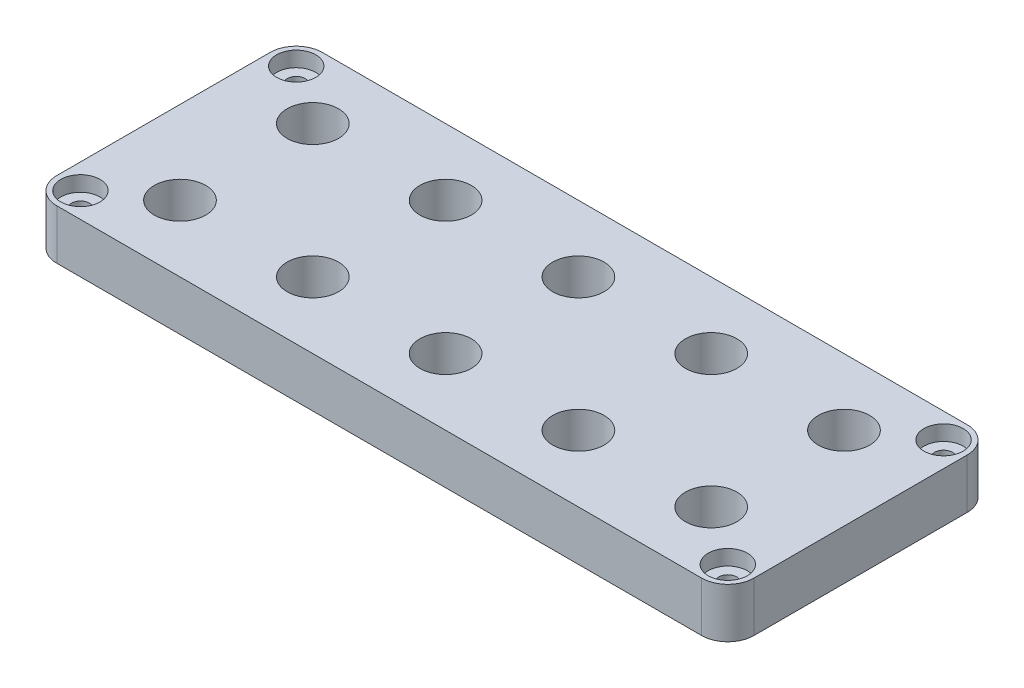
from build123d import *

# Parameters (mm, degrees)
SKETCH1_W           = 266.7
SKETCH1_H           = 101.6
SKETCH1_R           = 9.8425
SKETCH1_R_2         = 3.429
BOSS_EXTRUDE1_DEPTH = 19.05
FILLET1_R           = 10
SKETCH2_R           = 7.5
CUT_EXTRUDE1_DEPTH  = 5.842


with BuildPart() as part:
    # Sketch1 → Boss-Extrude1 (new body)
    with BuildSketch(Plane(origin=(0, 0, 0), x_dir=(1, 0, 0), z_dir=(0, 1, 0))):
        with Locations((133.35, 50.8)):
            Rectangle(SKETCH1_W, SKETCH1_H)
        with Locations(Location((31.75, 25.4, 0), (0, 0, 270))):  # turned: the seam where the file's is
            Circle(SKETCH1_R, mode=Mode.SUBTRACT)
        with Locations(Location((82.55, 25.4, 0), (0, 0, 270))):  # turned: the seam where the file's is
            Circle(SKETCH1_R, mode=Mode.SUBTRACT)
        with Locations(Location((133.35, 25.4, 0), (0, 0, 270))):  # turned: the seam where the file's is
            Circle(SKETCH1_R, mode=Mode.SUBTRACT)
        with Locations(Location((184.15, 25.4, 0), (0, 0, 270))):  # turned: the seam where the file's is
            Circle(SKETCH1_R, mode=Mode.SUBTRACT)
        with Locations(Location((234.95, 25.4, 0), (0, 0, 270))):  # turned: the seam where the file's is
            Circle(SKETCH1_R, mode=Mode.SUBTRACT)
        with Locations(Location((82.55, 76.2, 0), (0, 0, 270))):  # turned: the seam where the file's is
            Circle(SKETCH1_R, mode=Mode.SUBTRACT)
        with Locations(Location((133.35, 76.2, 0), (0, 0, 270))):  # turned: the seam where the file's is
            Circle(SKETCH1_R, mode=Mode.SUBTRACT)
        with Locations(Location((184.15, 76.2, 0), (0, 0, 270))):  # turned: the seam where the file's is
            Circle(SKETCH1_R, mode=Mode.SUBTRACT)
        with Locations(Location((234.95, 76.2, 0), (0, 0, 270))):  # turned: the seam where the file's is
            Circle(SKETCH1_R, mode=Mode.SUBTRACT)
        with Locations(Location((31.75, 76.2, 0), (0, 0, 270))):  # turned: the seam where the file's is
            Circle(SKETCH1_R, mode=Mode.SUBTRACT)
        with Locations(Location((9.525, 92.075, 0), (0, 0, 270))):  # turned: the seam where the file's is
            Circle(SKETCH1_R_2, mode=Mode.SUBTRACT)
        with Locations(Location((257.175, 92.075, 0), (0, 0, 90))):  # turned: the seam where the file's is
            Circle(SKETCH1_R_2, mode=Mode.SUBTRACT)
        with Locations(Location((9.525, 9.525, 0), (0, 0, 90))):  # turned: the seam where the file's is
            Circle(SKETCH1_R_2, mode=Mode.SUBTRACT)
        with Locations(Location((257.175, 9.525, 0), (0, 0, 270))):  # turned: the seam where the file's is
            Circle(SKETCH1_R_2, mode=Mode.SUBTRACT)
    extrude(amount=BOSS_EXTRUDE1_DEPTH)

    # Fillet1
    fillet1_edges = [part.edges().sort_by_distance(p)[0] for p in [
        (0, 9.525, -101.6),
        (266.7, 9.525, -101.6),
        (266.7, 9.525, 0),
        (0, 9.525, 0),
    ]]
    fillet(fillet1_edges, radius=FILLET1_R)

    # Sketch2 → Cut-Extrude1 (cut)
    with BuildSketch(Plane(origin=(0, 19.05, 0), x_dir=(1, 0, 0), z_dir=(0, 1, 0))):
        with Locations(Location((9.525, 92.075, 0), (0, 0, 270))):  # turned: the seam where the file's is
            Circle(SKETCH2_R)
        with Locations(Location((257.175, 92.075, 0), (0, 0, 270))):  # turned: the seam where the file's is
            Circle(SKETCH2_R)
        with Locations(Location((257.175, 9.525, 0), (0, 0, 270))):  # turned: the seam where the file's is
            Circle(SKETCH2_R)
        with Locations(Location((9.525, 9.525, 0), (0, 0, 270))):  # turned: the seam where the file's is
            Circle(SKETCH2_R)
    extrude(amount=-CUT_EXTRUDE1_DEPTH, mode=Mode.SUBTRACT)


solid = part.part
